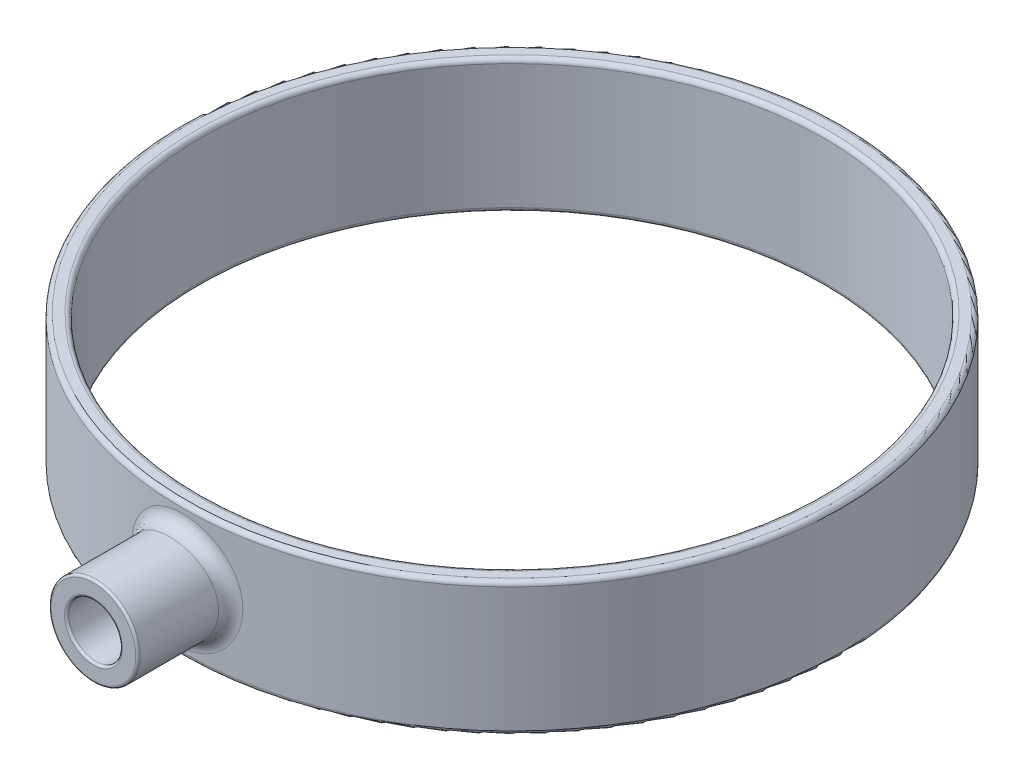
from build123d import *

# Parameters (mm, degrees)
SKETCH1_W                = 2
SKETCH1_H                = 15
BOSS_EXTRUDE1_REACH      = 94.094
BOSS_EXTRUDE1_END_RADIUS = 37
SKETCH2_R                = 5
SKETCH4_R                = 3
CUT_EXTRUDE1_DEPTH       = 10
FILLET2_R                = 0.25
FILLET3_R                = 1.5
FILLET4_R                = 0.5


with BuildPart() as part:
    # Sketch1 → Revolve1 (revolve)
    with BuildSketch(Plane.XY, mode=Mode.PRIVATE) as revolve1_sk:
        with Locations((36, 0)):
            Rectangle(SKETCH1_W, SKETCH1_H)
    revolve(revolve1_sk.sketch.rotate(Axis((0, 15.259118644, 0), (0, -1, 0)), 90), axis=Axis((0, 15.259118644, 0), (0, -1, 0)))

    # Boss-Extrude1: up to this cylinder (the profile starts outside it)
    boss_extrude1_end = Plane(origin=(0, 0, 0), z_dir=(0, 1, 0)) * Cylinder(BOSS_EXTRUDE1_END_RADIUS, 263.188, mode=Mode.PRIVATE)
    # Sketch2 → Boss-Extrude1 (add, up to the surface)
    with BuildSketch(Plane.XY.offset(47), mode=Mode.PRIVATE) as boss_extrude1_sk1:
        Circle(SKETCH2_R)
    boss_extrude1_tool1 = extrude(boss_extrude1_sk1.sketch, amount=-BOSS_EXTRUDE1_REACH, mode=Mode.PRIVATE) - boss_extrude1_end
    add(boss_extrude1_tool1.solids().sort_by_distance((0, 0, 47))[0])

    # Sketch4 → Cut-Extrude1 (cut)
    with BuildSketch(Plane.XY.offset(47)):
        Circle(SKETCH4_R)
    extrude(amount=-CUT_EXTRUDE1_DEPTH, mode=Mode.SUBTRACT)

    # Fillet2
    fillet2_edges = [part.edges().sort_by_distance(p)[0] for p in [
        (-5, 0, 47),
        (-3, 0, 47),
    ]]
    fillet(fillet2_edges, radius=FILLET2_R)

    # Fillet3
    fillet3_edges = [part.edges().sort_by_distance(p)[0] for p in [
        (-5, 0, 36.66060556),
    ]]
    fillet(fillet3_edges, radius=FILLET3_R)

    # Fillet4
    fillet4_edges = [part.edges().sort_by_distance(p)[0] for p in [
        (0, 7.5, -35),
        (0, 7.5, -37),
        (0, -7.5, -37),
        (0, -7.5, -35),
    ]]
    fillet(fillet4_edges, radius=FILLET4_R)


solid = part.part
